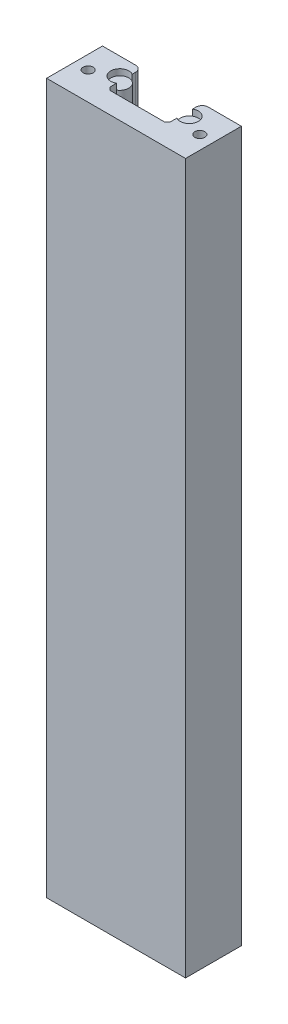
from build123d import *

# Parameters (mm, degrees)
BOSS_EXTRUDE1_DEPTH   = 117.5
SKETCH2_R             = 2.95
BOSS_EXTRUDE2_DEPTH   = 115.5
BOSS_EXTRUDE2_2_DEPTH = 115.5
CHAMFER1_SIZE         = 1
FILLET1_R             = 2
SKETCH3_R             = 1.65
CUT_EXTRUDE1_DEPTH    = 25
SKETCH4_R             = 1.65
CUT_EXTRUDE2_DEPTH    = 25


with BuildPart() as part:
    # Sketch1 → Boss-Extrude1 (new body, symmetric)
    with BuildSketch(Plane(origin=(0, 0, 0), x_dir=(1, 0, 0), z_dir=(0, 1, 0))):
        with BuildLine():
            Line((23, 0), (-23, 0))
            Line((-23, 0), (-23, 18.5))
            Line((-23, 18.5), (-10, 18.5))
            Line((-10, 18.5), (-10, 15.348076211))
            ThreePointArc((-10, 15.348076211), (-14.5, 12.75), (-10, 10.151923789))
            Line((-10, 10.151923789), (-10, 7))
            Line((-10, 7), (10, 7))
            Line((10, 7), (10, 10.151923789))
            ThreePointArc((10, 10.151923789), (14.5, 12.75), (10, 15.348076211))
            Line((10, 15.348076211), (10, 18.5))
            Line((10, 18.5), (23, 18.5))
            Line((23, 18.5), (23, 0))
        make_face()
    extrude(amount=BOSS_EXTRUDE1_DEPTH, both=True)

    # Chamfer1
    chamfer1_edges = [part.edges().sort_by_distance(p)[0] for p in [
        (-10, 0, -7),
        (10, 0, -7),
    ]]
    chamfer(chamfer1_edges, length=CHAMFER1_SIZE)

    # Fillet1
    fillet1_edges = [part.edges().sort_by_distance(p)[0] for p in [
        (-10, 0, -18.5),
        (10, 0, -18.5),
    ]]
    fillet(fillet1_edges, radius=FILLET1_R)

    # Sketch3 → Cut-Extrude1 (cut)
    with BuildSketch(Plane(origin=(0, 117.5, 0), x_dir=(1, 0, 0), z_dir=(0, 1, 0))):
        with Locations((-18.5, 9.25)):
            Circle(SKETCH3_R)
        with Locations((18.5, 9.25)):
            Circle(SKETCH3_R)
    extrude(amount=-CUT_EXTRUDE1_DEPTH, mode=Mode.SUBTRACT)

    # Sketch4 → Cut-Extrude2 (cut)
    with BuildSketch(Plane.XZ.offset(117.5)):
        with Locations((-18.5, -14.25)):
            Circle(SKETCH4_R)
        with Locations((-18.5, -4.25)):
            Circle(SKETCH4_R)
        with Locations((18.5, -14.25)):
            Circle(SKETCH4_R)
        with Locations((18.5, -4.25)):
            Circle(SKETCH4_R)
    extrude(amount=-CUT_EXTRUDE2_DEPTH, mode=Mode.SUBTRACT)


with BuildPart() as body_2:
    # Sketch2 → Boss-Extrude2 (new body, symmetric)
    with BuildSketch(Plane(origin=(0, 0, 0), x_dir=(1, 0, 0), z_dir=(0, 1, 0))):
        with Locations((-11.5, 12.75)):
            Circle(SKETCH2_R)
    extrude(amount=BOSS_EXTRUDE2_DEPTH, both=True)


with BuildPart() as body_3:
    # Sketch2 → Boss-Extrude2 2 (new body, symmetric)
    with BuildSketch(Plane(origin=(0, 0, 0), x_dir=(1, 0, 0), z_dir=(0, 1, 0))):
        with Locations((11.5, 12.75)):
            Circle(SKETCH2_R)
    extrude(amount=BOSS_EXTRUDE2_2_DEPTH, both=True)


solid = Compound([part.part, body_2.part, body_3.part])
